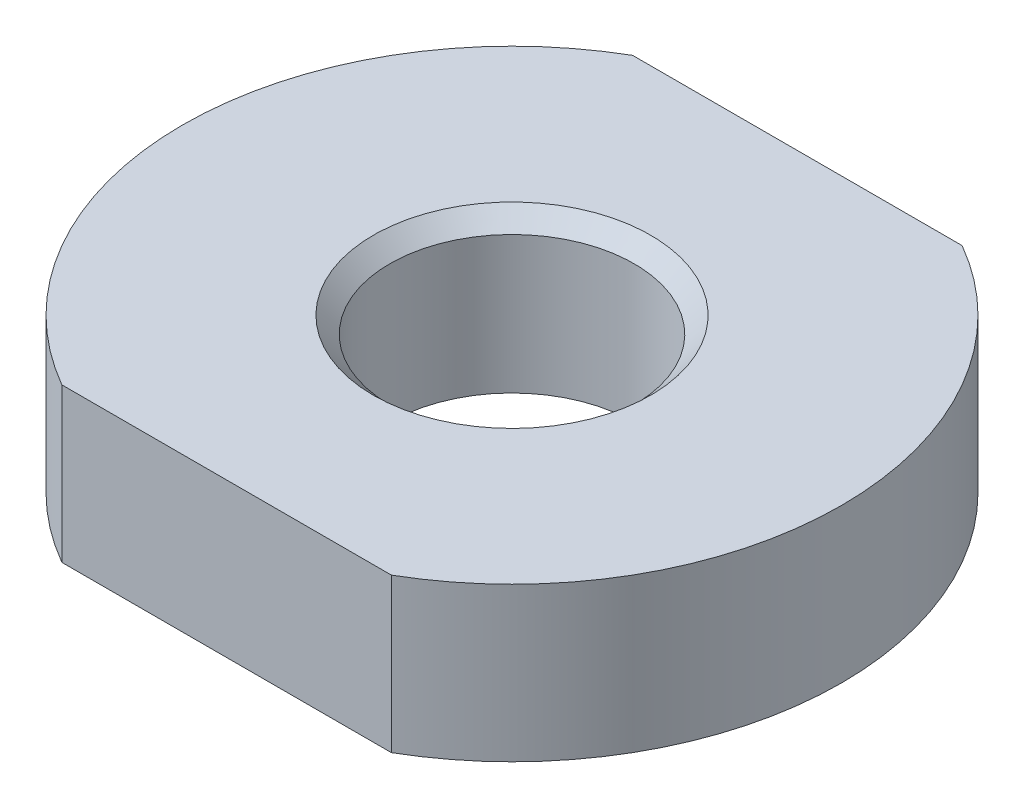
from build123d import *

# Parameters (mm, degrees)
SKETCH1_R           = 4.45
BOSS_EXTRUDE1_DEPTH = 5.6
CHAMFER1_SIZE       = 0.6


with BuildPart() as part:
    # Sketch1 → Boss-Extrude1 (new body)
    with BuildSketch(Plane(origin=(0, 0, 0), x_dir=(1, 0, 0), z_dir=(0, 1, 0))):
        with BuildLine():
            Line((6, 10.392304845), (-6, 10.392304845))
            ThreePointArc((-6, 10.392304845), (-12, 0), (-6, -10.392304845))
            Line((-6, -10.392304845), (6, -10.392304845))
            ThreePointArc((6, -10.392304845), (12, 0), (6, 10.392304845))
        make_face()
        Circle(SKETCH1_R, mode=Mode.SUBTRACT)
    extrude(amount=BOSS_EXTRUDE1_DEPTH)

    # Chamfer1
    chamfer1_edges = [part.edges().sort_by_distance(p)[0] for p in [
        (-4.45, 5.6, 0),
    ]]
    chamfer(chamfer1_edges, length=CHAMFER1_SIZE)


solid = part.part
